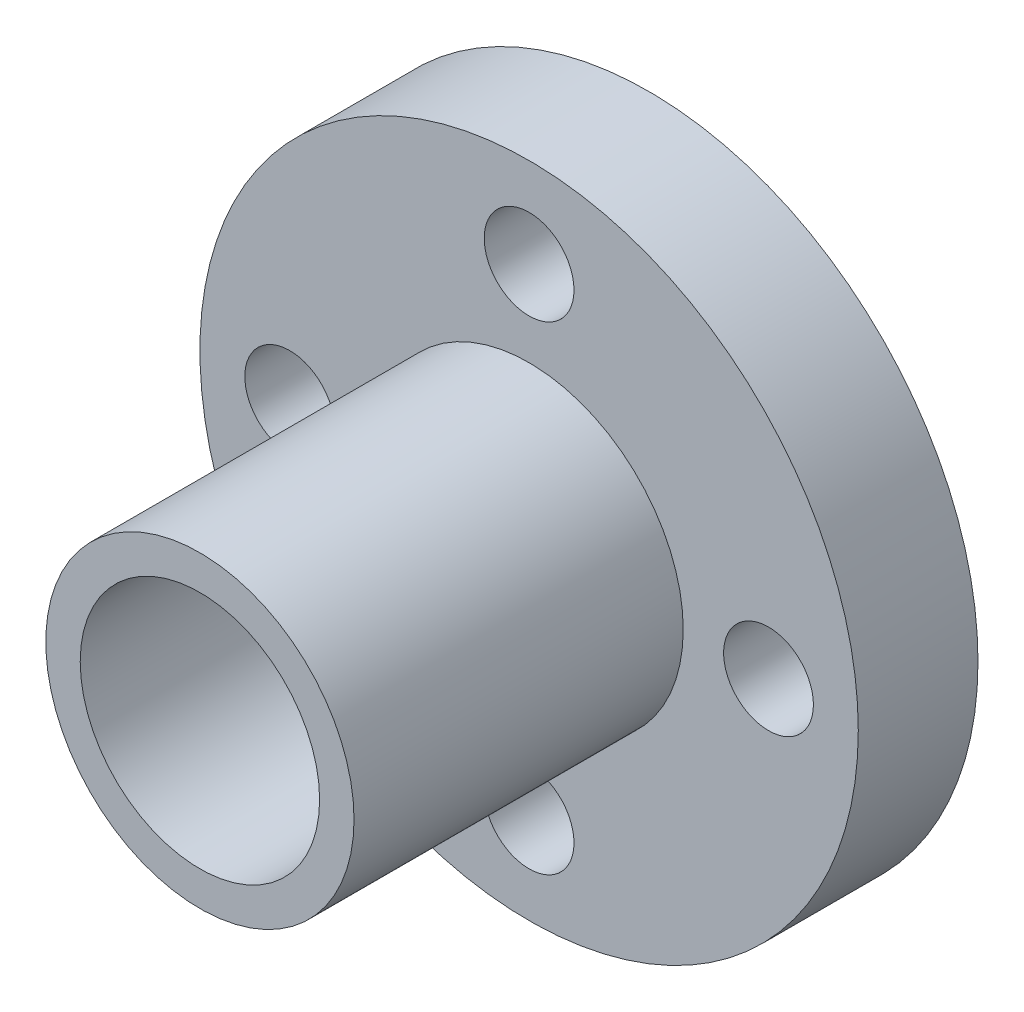
from build123d import *

# Parameters (mm, degrees)
SKETCH1_R           = 11
BOSS_EXTRUDE1_DEPTH = 4
SKETCH2_R           = 5.15
BOSS_EXTRUDE2_DEPTH = 11
SKETCH3_R           = 4
CUT_EXTRUDE1_DEPTH  = 16
SKETCH4_R           = 1.5
CUT_EXTRUDE2_DEPTH  = 5


with BuildPart() as part:
    # Sketch1 → Boss-Extrude1 (new body)
    with BuildSketch(Plane.XY):
        Circle(SKETCH1_R)
    extrude(amount=BOSS_EXTRUDE1_DEPTH)

    # Sketch2 → Boss-Extrude2 (add)
    with BuildSketch(Plane.XY.offset(4)):
        Circle(SKETCH2_R)
    extrude(amount=BOSS_EXTRUDE2_DEPTH)

    # Sketch3 → Cut-Extrude1 (cut, through all)
    with BuildSketch(Plane.XY.offset(15)):
        Circle(SKETCH3_R)
    extrude(amount=-CUT_EXTRUDE1_DEPTH, mode=Mode.SUBTRACT)

    # Sketch4 → Cut-Extrude2 (cut, through all)
    with BuildSketch(Plane.XY.offset(4)):
        with Locations((0, 8)):
            Circle(SKETCH4_R)
        with Locations((8, 0)):
            Circle(SKETCH4_R)
        with Locations((0, -8)):
            Circle(SKETCH4_R)
        with Locations((-8, 0)):
            Circle(SKETCH4_R)
    extrude(amount=-CUT_EXTRUDE2_DEPTH, mode=Mode.SUBTRACT)


solid = part.part
